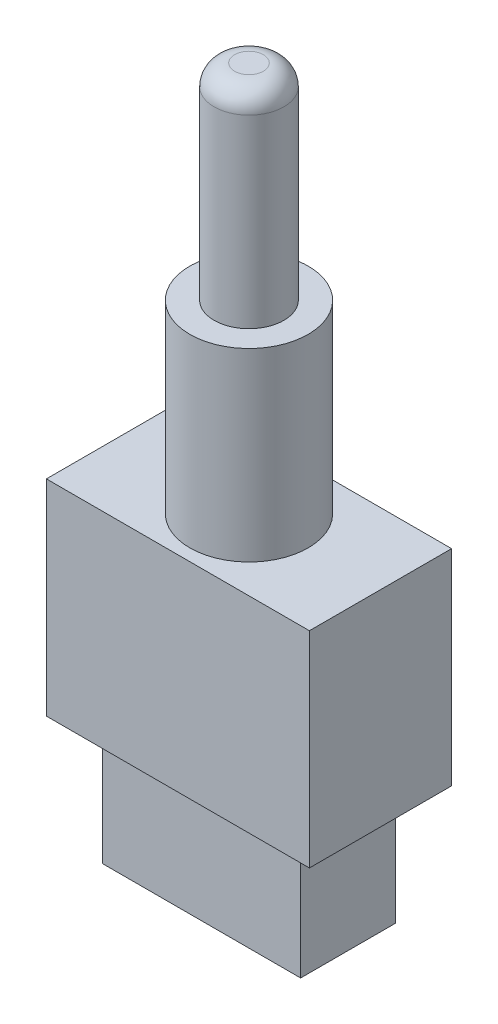
from build123d import *

# Parameters (mm, degrees)
SKETCH1_W           = 12.8
SKETCH1_H           = 6.92
BOSS_EXTRUDE1_DEPTH = 10
SKETCH2_R           = 2.88
BOSS_EXTRUDE2_DEPTH = 9
SKETCH3_R           = 1.699009251
BOSS_EXTRUDE3_DEPTH = 10
FILLET1_R           = 1
SKETCH4_W           = 9.648664286
SKETCH4_H           = 4.621814488
BOSS_EXTRUDE4_DEPTH = 6


with BuildPart() as part:
    # Sketch1 → Boss-Extrude1 (new body)
    with BuildSketch(Plane(origin=(0, 0, 0), x_dir=(1, 0, 0), z_dir=(0, 1, 0))):
        Rectangle(SKETCH1_W, SKETCH1_H)
    extrude(amount=BOSS_EXTRUDE1_DEPTH)

    # Sketch2 → Boss-Extrude2 (add)
    with BuildSketch(Plane(origin=(0, 10, 0), x_dir=(1, 0, 0), z_dir=(0, 1, 0))):
        Circle(SKETCH2_R)
    extrude(amount=BOSS_EXTRUDE2_DEPTH)

    # Sketch3 → Boss-Extrude3 (add)
    with BuildSketch(Plane(origin=(0, 19, 0), x_dir=(1, 0, 0), z_dir=(0, 1, 0))):
        Circle(SKETCH3_R)
    extrude(amount=BOSS_EXTRUDE3_DEPTH)

    # Fillet1
    fillet1_edges = [part.edges().sort_by_distance(p)[0] for p in [
        (-1.699009251, 29, 0),
    ]]
    fillet(fillet1_edges, radius=FILLET1_R)

    # Sketch4 → Boss-Extrude4 (add)
    with BuildSketch(Plane.XZ):
        Rectangle(SKETCH4_W, SKETCH4_H)
    extrude(amount=BOSS_EXTRUDE4_DEPTH)


solid = part.part
